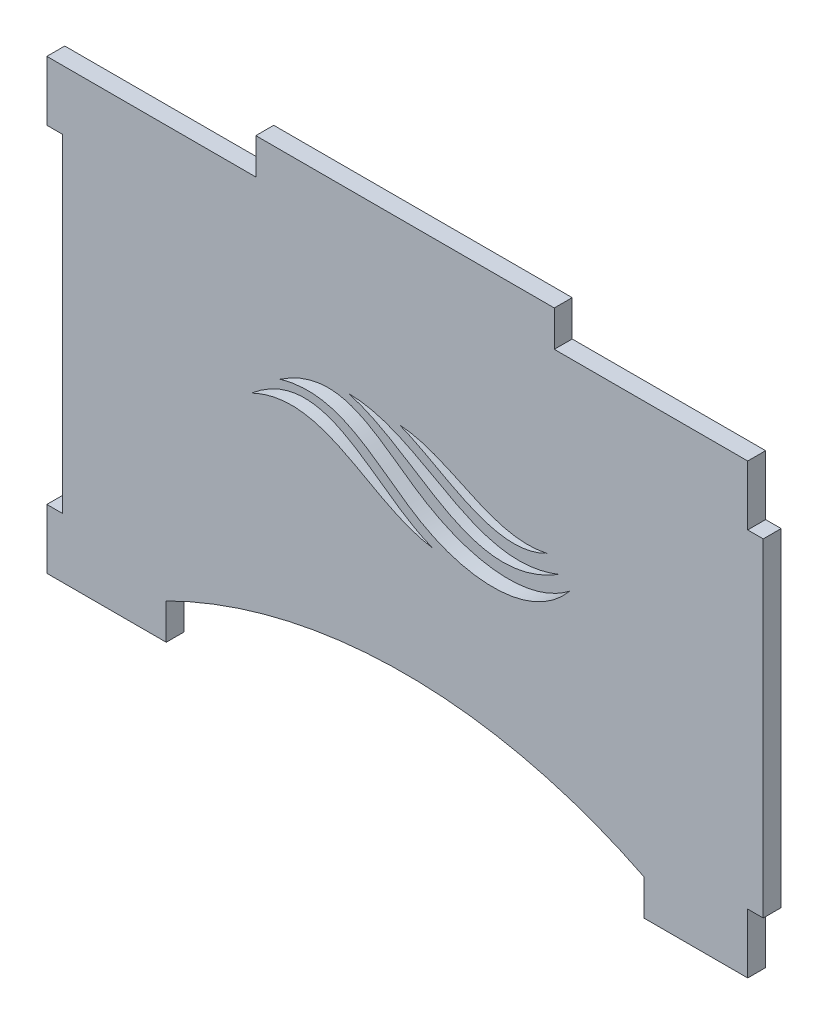
from build123d import *

# Parameters (mm, degrees)
BOSS_EXTRUDE1_DEPTH = 3
CUT_EXTRUDE1_DEPTH  = 4
CUT_EXTRUDE3_DEPTH  = 4.0000001


with BuildPart() as part:
    # Sketch1 → Boss-Extrude1 (new body)
    with BuildSketch(Plane.XY):
        Polygon((-58.7, -75), (-38.7, -75), (-38.7, -69), (41.3, -69), (41.3, -75), (58.7, -75), (58.7, -65), (61.3, -65), (61.3, -10), (58.7, -10), (58.7, 0), (26.3, 0), (26.3, 6), (-23.7, 6), (-23.7, 0), (-58.7, 0), (-58.7, -10), (-56.1, -10), (-56.1, -65), (-58.7, -65), align=None)
    extrude(amount=BOSS_EXTRUDE1_DEPTH)

    # Sketch2 → Cut-Extrude1 (cut, through all)
    with BuildSketch(Plane(origin=(0, 0, 0), x_dir=(-1, 0, 0), z_dir=(0, 0, -1))):
        with BuildLine():
            add(Edge.make_bspline(
                [(24.433398527, -31.711635794), (12.086875589, -21.375223364), (4.140193098, -35.358229775), (-5.972759652, -39.022471709)],
                knots=[0, 0, 0, 0, 1, 1, 1, 1], degree=3))
            add(Edge.make_bspline(
                [(24.433398527, -31.711635794), (12.266801911, -25.891579846), (4.786651273, -37.542126637), (-5.972759652, -39.022471709)],
                knots=[0, 0, 0, 0, 1, 1, 1, 1], degree=3))
        make_face()
        with BuildLine():
            add(Edge.make_bspline(
                [(19.633876366, -27.309577158), (8.736929361, -24.137857676), (-2.141100893, -40.478091734), (-22.792881591, -41.192187033), (-28.893422578, -33.772468692)],
                knots=[0, 0, 0, 0, 0.516039473, 1, 1, 1, 1], degree=3))
            add(Edge.make_bspline(
                [(19.633876366, -27.309577158), (9.023428577, -20.186786928), (-2.404229512, -35.749210026), (-21.92167278, -39.158153915), (-28.893422578, -33.772468692)],
                knots=[0, 0, 0, 0, 0.521405392, 1, 1, 1, 1], degree=3))
        make_face()
        with BuildLine():
            add(Edge.make_bspline(
                [(8.169819804, -23.626017478), (-3.788465932, -26.918738654), (-12.420801252, -41.286617905), (-27.125100941, -32.24653048)],
                knots=[0, 0, 0, 0, 1, 1, 1, 1], degree=3))
            add(Edge.make_bspline(
                [(8.169819804, -23.626017478), (-4.800169657, -23.753336514), (-12.720211609, -38.015113151), (-27.125100941, -32.24653048)],
                knots=[0, 0, 0, 0, 1, 1, 1, 1], degree=3))
        make_face()
        with BuildLine():
            add(Edge.make_bspline(
                [(-0.374797507, -23.912294014), (-7.802045912, -26.759848505), (-16.403312917, -34.789264508), (-25.125919349, -30.178411592)],
                knots=[0, 0, 0, 0, 1, 1, 1, 1], degree=3))
            add(Edge.make_bspline(
                [(-0.374797507, -23.912294014), (-9.180167192, -24.486819088), (-15.773948384, -32.398766596), (-25.125919349, -30.178411592)],
                knots=[0, 0, 0, 0, 1, 1, 1, 1], degree=3))
        make_face()
    extrude(amount=-CUT_EXTRUDE1_DEPTH, mode=Mode.SUBTRACT)

    # Sketch4 → Cut-Extrude3 (cut, through all)
    with BuildSketch(Plane(origin=(0, 0, 0), x_dir=(-1, 0, 0), z_dir=(0, 0, -1))):
        with BuildLine():
            Line((-41.3, -69), (38.7, -69))
            ThreePointArc((38.7, -69), (-1.3, -59.5572809), (-41.3, -69))
        make_face()
    extrude(amount=-CUT_EXTRUDE3_DEPTH, mode=Mode.SUBTRACT)


solid = part.part
